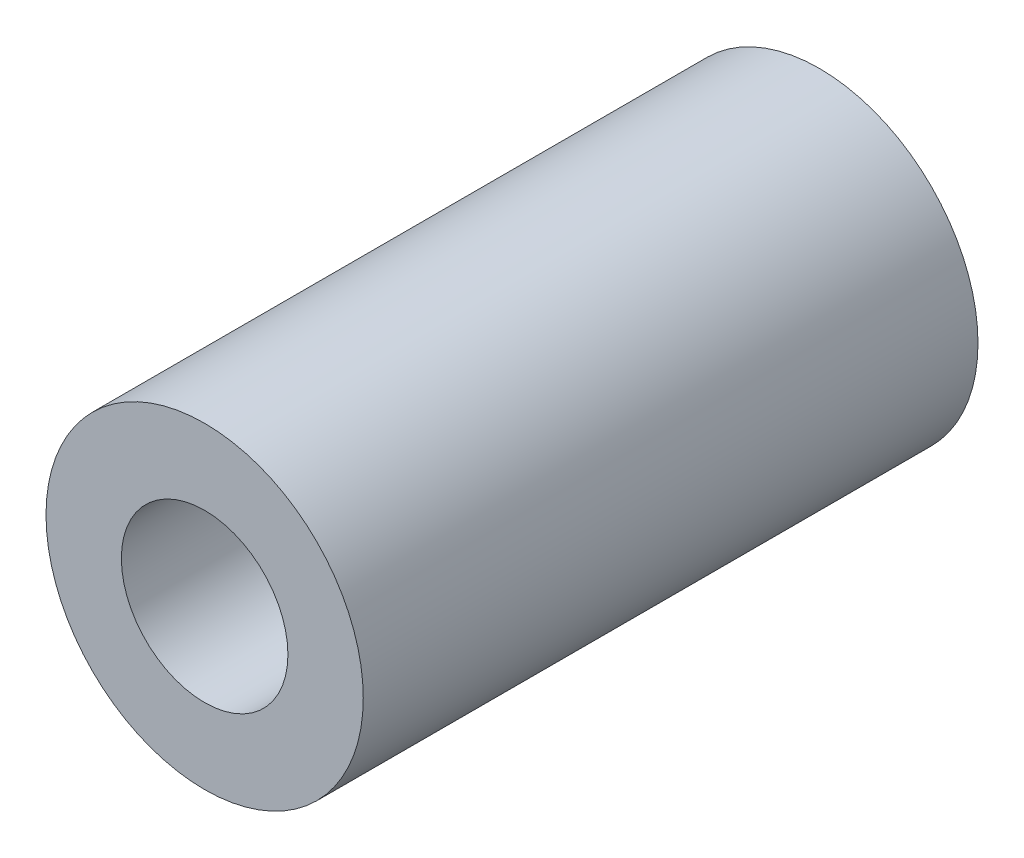
from build123d import *

# Parameters (mm, degrees)
SKETCH_1_R      = 4
SKETCH_1_R_2    = 2.1
EXTRUDE_1_DEPTH = 15.5


with BuildPart() as part:
    # ｽｹｯﾁ1 → ﾎﾞｽ - 押し出し1 (new body)
    with BuildSketch(Plane.XY):
        Circle(SKETCH_1_R)
        Circle(SKETCH_1_R_2, mode=Mode.SUBTRACT)
    extrude(amount=EXTRUDE_1_DEPTH)


solid = part.part
